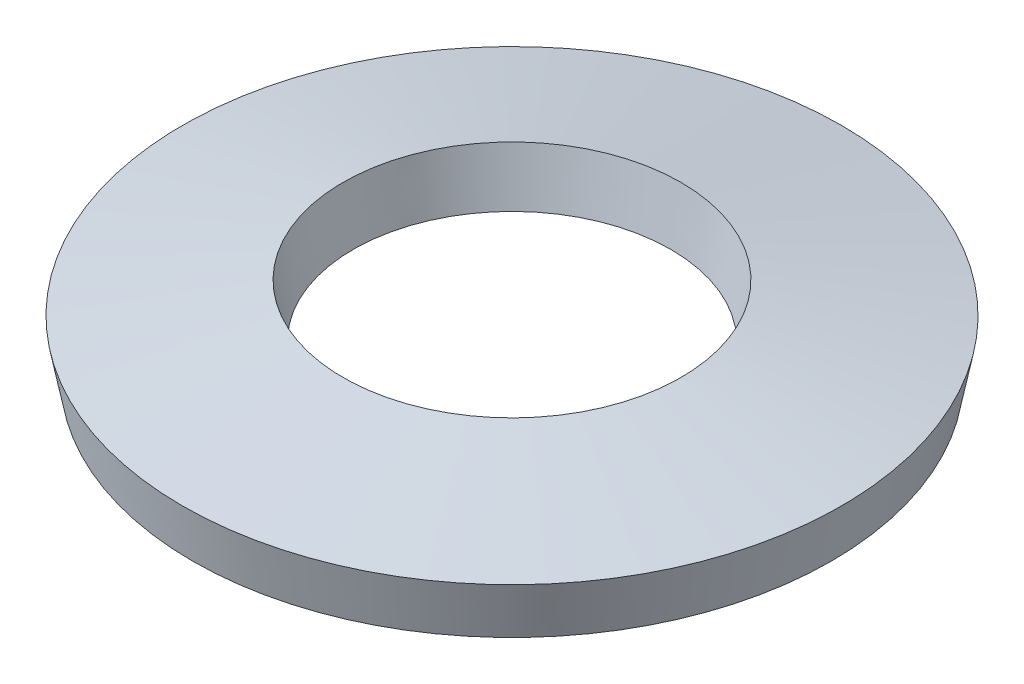
from build123d import *


with BuildPart() as part:
    # Sketch1 → Revolve1 (revolve)
    with BuildSketch(Plane.XY):
        Polygon((5.329746589, 0), (2.65, 0.516250162), (2.820253411, 1.4), (5.5, 0.883749838), align=None)
    revolve(axis=Axis((0, 0, 0), (0, 1, 0)))


solid = part.part
